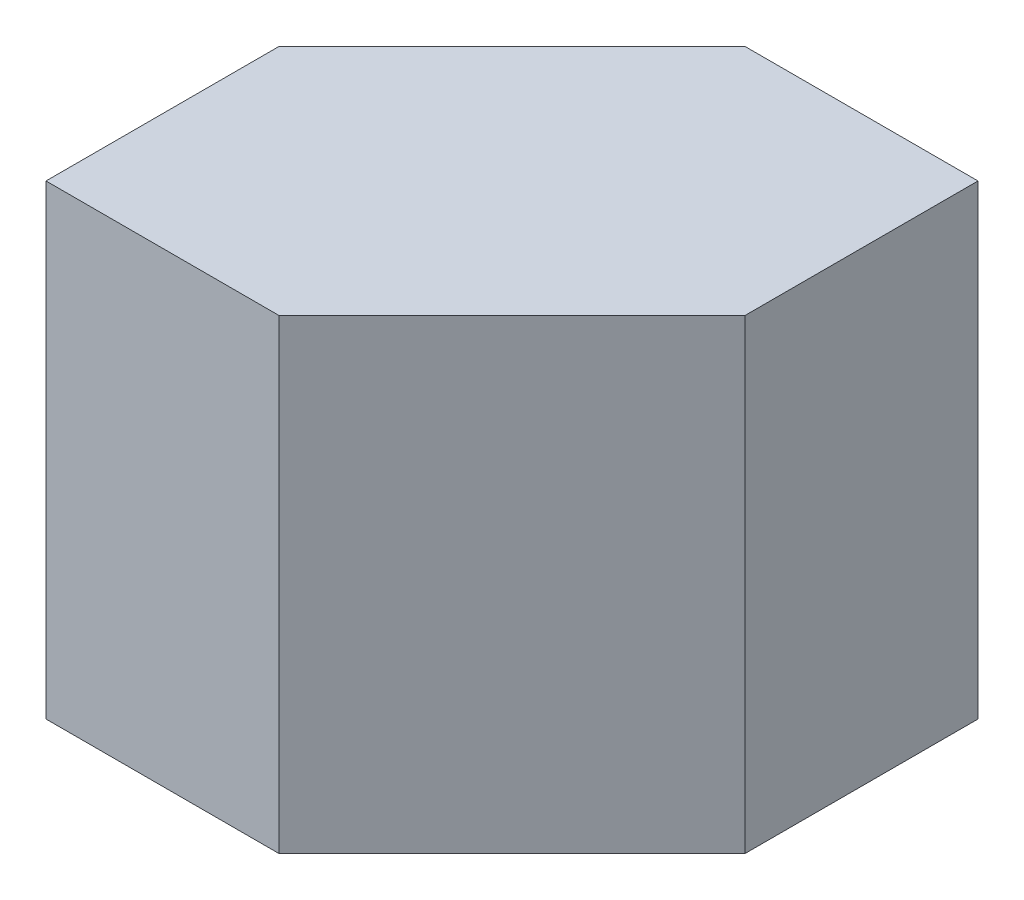
from build123d import *

# Parameters (mm, degrees)
SKETCH1_W           = 20
SKETCH1_H           = 20
BOSS_EXTRUDE1_DEPTH = 20
CUT_EXTRUDE1_DEPTH  = 20
CUT_EXTRUDE2_DEPTH  = 20


with BuildPart() as part:
    # Sketch1 → Boss-Extrude1 (new body)
    with BuildSketch(Plane.XY):
        with Locations((10, 10)):
            Rectangle(SKETCH1_W, SKETCH1_H)
    extrude(amount=BOSS_EXTRUDE1_DEPTH)

    # Sketch2 → Cut-Extrude1 (cut)
    with BuildSketch(Plane(origin=(0, 20, 0), x_dir=(1, 0, 0), z_dir=(0, 1, 0))):
        Polygon((20, -20), (20, -10), (10, -20), align=None)
    extrude(amount=-CUT_EXTRUDE1_DEPTH, mode=Mode.SUBTRACT)

    # Sketch3 → Cut-Extrude2 (cut)
    with BuildSketch(Plane(origin=(0, 20, 0), x_dir=(1, 0, 0), z_dir=(0, 1, 0))):
        Polygon((0, 0), (10, 0), (0, -10), align=None)
    extrude(amount=-CUT_EXTRUDE2_DEPTH, mode=Mode.SUBTRACT)


solid = part.part
